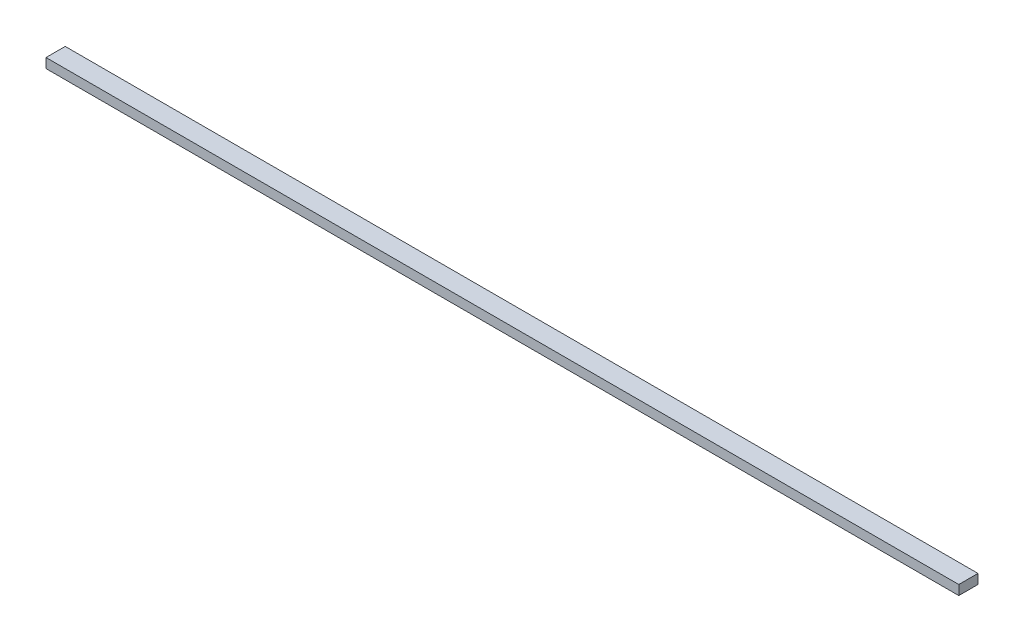
from build123d import *

# Parameters (mm, degrees)
ESBO_O1_W                = 4750
ESBO_O1_H                = 50
RESSALTO_EXTRUS_O1_DEPTH = 100


with BuildPart() as part:
    # Esboço1 → Ressalto-extrusão1 (new body)
    with BuildSketch(Plane.XY):
        with Locations((2375, 25)):
            Rectangle(ESBO_O1_W, ESBO_O1_H)
    extrude(amount=RESSALTO_EXTRUS_O1_DEPTH)


solid = part.part
